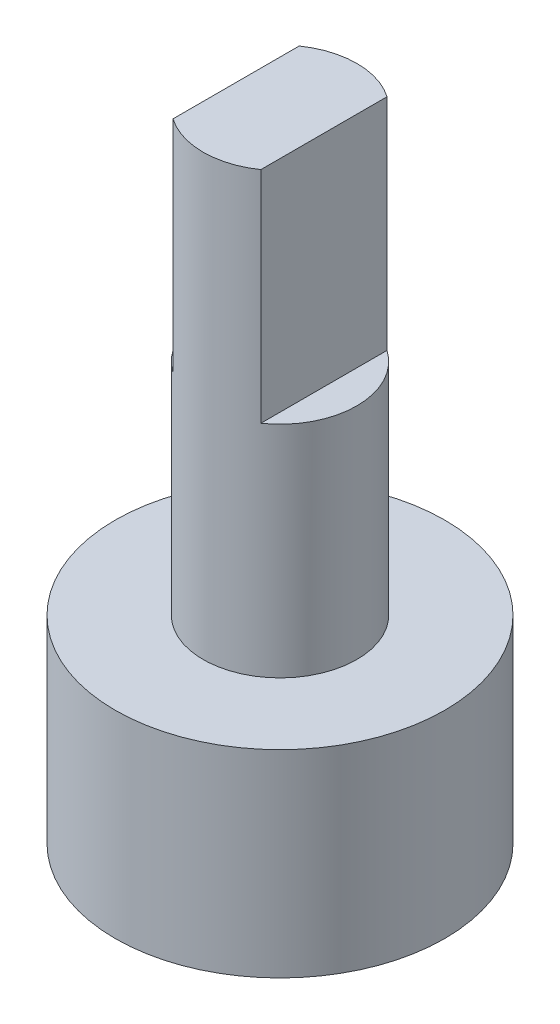
from build123d import *

# Parameters (mm, degrees)
SKETCH1_R           = 1.75
BOSS_EXTRUDE1_DEPTH = 10
CUT_EXTRUDE1_DEPTH  = 5
SKETCH3_R           = 3.75
BOSS_EXTRUDE2_DEPTH = 4.5
SKETCH4_R           = 3.25
CUT_EXTRUDE2_DEPTH  = 2.5
SKETCH5_R           = 2.5
CUT_EXTRUDE3_DEPTH  = 1


with BuildPart() as part:
    # Sketch1 → Boss-Extrude1 (new body)
    with BuildSketch(Plane(origin=(0, 0, 0), x_dir=(1, 0, 0), z_dir=(0, 1, 0))):
        Circle(SKETCH1_R)
    extrude(amount=BOSS_EXTRUDE1_DEPTH)

    # Sketch2 → Cut-Extrude1 (cut)
    with BuildSketch(Plane(origin=(0, 10, 0), x_dir=(1, 0, 0), z_dir=(0, 1, 0))):
        with BuildLine():
            Line((-1, 1.436140662), (-1, -1.436140662))
            ThreePointArc((-1, -1.436140662), (-1.75, 0), (-1, 1.436140662))
        make_face()
        with BuildLine():
            Line((1, 1.436140662), (1, -1.436140662))
            ThreePointArc((1, -1.436140662), (1.75, 0), (1, 1.436140662))
        make_face()
    extrude(amount=-CUT_EXTRUDE1_DEPTH, mode=Mode.SUBTRACT)

    # Sketch3 → Boss-Extrude2 (add)
    with BuildSketch(Plane.XZ):
        Circle(SKETCH3_R)
    extrude(amount=BOSS_EXTRUDE2_DEPTH)

    # Sketch4 → Cut-Extrude2 (cut)
    with BuildSketch(Plane.XZ.offset(4.5)):
        Circle(SKETCH4_R)
    extrude(amount=-CUT_EXTRUDE2_DEPTH, mode=Mode.SUBTRACT)

    # Sketch5 → Cut-Extrude3 (cut)
    with BuildSketch(Plane.XZ.offset(2)):
        Circle(SKETCH5_R)
    extrude(amount=-CUT_EXTRUDE3_DEPTH, mode=Mode.SUBTRACT)


solid = part.part
